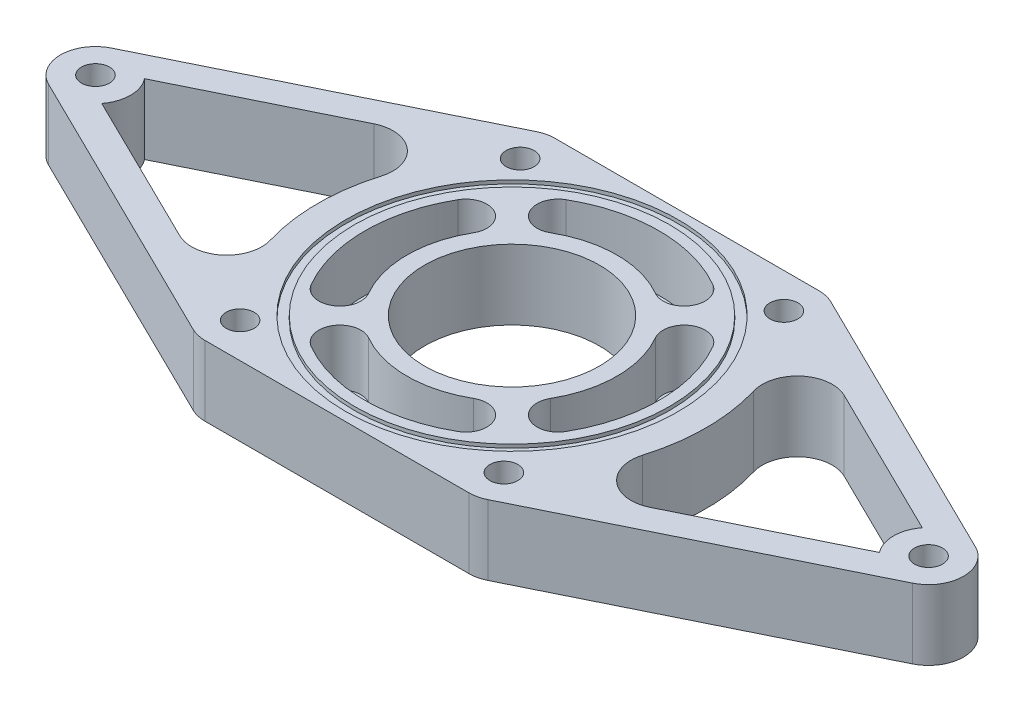
from build123d import *

# Parameters (mm, degrees)
BOSS_EXTRUDE1_DEPTH = 20
SKETCH2_R           = 47.5
SKETCH2_R_2         = 45
CUT_EXTRUDE1_DEPTH  = 1
CUT_EXTRUDE2_DEPTH  = 16
CIRPATTERN1_COUNT   = 4
SKETCH4_R           = 25
CUT_EXTRUDE3_DEPTH  = 21
SKETCH6_R           = 4
CUT_EXTRUDE4_DEPTH  = 21
CUT_EXTRUDE5_DEPTH  = 21
FILLET1_R           = 10
SKETCH9_R           = 4
CUT_EXTRUDE6_DEPTH  = 21


with BuildPart() as part:
    # Sketch1 → Boss-Extrude1 (new body)
    with BuildSketch(Plane(origin=(0, 0, 0), x_dir=(1, 0, 0), z_dir=(0, 1, 0))):
        with BuildLine():
            Line((-40, -50), (40, -50))
            Line((40, -50), (123.413509856, -8.973345572))
            ThreePointArc((123.413509856, -8.973345572), (129, 0), (123.413509856, 8.973345572))
            Line((123.413509856, 8.973345572), (40, 50))
            Line((40, 50), (-40, 50))
            Line((-40, 50), (-123.413509856, 8.973345572))
            ThreePointArc((-123.413509856, 8.973345572), (-129, 0), (-123.413509856, -8.973345572))
            Line((-123.413509856, -8.973345572), (-40, -50))
        make_face()
    extrude(amount=BOSS_EXTRUDE1_DEPTH)

    # Sketch2 → Cut-Extrude1 (cut)
    with BuildSketch(Plane(origin=(0, 20, 0), x_dir=(1, 0, 0), z_dir=(0, 1, 0))):
        with Locations(Location((0, 0, 0), (0, 0, 270))):  # turned: the seam where the file's is
            Circle(SKETCH2_R)
        with Locations(Location((0, 0, 0), (0, 0, 270))):  # turned: the seam where the file's is
            Circle(SKETCH2_R_2, mode=Mode.SUBTRACT)
    extrude(amount=-CUT_EXTRUDE1_DEPTH, mode=Mode.SUBTRACT)

    # Sketch3 → Cut-Extrude2 (cut)
    with BuildSketch(Plane(origin=(0, 20, 0), x_dir=(1, 0, 0), z_dir=(0, 1, 0))):
        with BuildLine():
            ThreePointArc((36.373066959, -21), (42, 0), (36.373066959, 21))
            ThreePointArc((36.373066959, 21), (28.176914536, 23.196152423), (25.980762114, 15))
            ThreePointArc((25.980762114, 15), (30, 0), (25.980762114, -15))
            ThreePointArc((25.980762114, -15), (28.176914536, -23.196152423), (36.373066959, -21))
        make_face()
    cut_extrude2 = extrude(amount=-CUT_EXTRUDE2_DEPTH, mode=Mode.SUBTRACT)

    # CirPattern1: Cut-Extrude2 ×4 about axis
    cirpattern1_axis = Axis((0, 0, 0), (0, 1, 0))
    for i in range(1, CIRPATTERN1_COUNT):
        add(cut_extrude2.rotate(cirpattern1_axis, i * 360 / CIRPATTERN1_COUNT), mode=Mode.SUBTRACT)

    # Sketch4 → Cut-Extrude3 (cut, through all)
    with BuildSketch(Plane(origin=(0, 20, 0), x_dir=(1, 0, 0), z_dir=(0, 1, 0))):
        with Locations(Location((0, 0, 0), (0, 0, 270))):  # turned: the seam where the file's is
            Circle(SKETCH4_R)
    extrude(amount=-CUT_EXTRUDE3_DEPTH, mode=Mode.SUBTRACT)

    # Sketch6 → Cut-Extrude4 (cut, through all)
    with BuildSketch(Plane(origin=(0, 20, 0), x_dir=(1, 0, 0), z_dir=(0, 1, 0))):
        with Locations(Location((-119, 0, 0), (0, 0, 270))):  # turned: the seam where the file's is
            Circle(SKETCH6_R)
        with Locations(Location((119, 0, 0), (0, 0, 270))):  # turned: the seam where the file's is
            Circle(SKETCH6_R)
    extrude(amount=-CUT_EXTRUDE4_DEPTH, mode=Mode.SUBTRACT)

    # Sketch8 → Cut-Extrude5 (cut, through all)
    with BuildSketch(Plane(origin=(0, 20, 0), x_dir=(1, 0, 0), z_dir=(0, 1, 0))):
        with BuildLine():
            Line((-67.173638652, 27.719444727), (-111.090654796, 6.119007963))
            ThreePointArc((-111.090654796, 6.119007963), (-109, 0), (-111.090654796, -6.119007963))
            Line((-111.090654796, -6.119007963), (-67.173638652, -27.719444727))
            ThreePointArc((-67.173638652, -27.719444727), (-56.30285419, -26.381778867), (-53.178429743, -15.884099284))
            ThreePointArc((-53.178429743, -15.884099284), (-55.5, 0), (-53.178429743, 15.884099284))
            ThreePointArc((-53.178429743, 15.884099284), (-56.30285419, 26.381778867), (-67.173638652, 27.719444727))
        make_face()
    cut_extrude5 = extrude(amount=-CUT_EXTRUDE5_DEPTH, mode=Mode.SUBTRACT)

    # Mirror1: Cut-Extrude5 across plane
    add(cut_extrude5.mirror(Plane(origin=(0, 0, 0), x_dir=(0, 0, 1), z_dir=(1, 0, 0))), mode=Mode.SUBTRACT)

    # Fillet1
    fillet1_edges = [part.edges().sort_by_distance(p)[0] for p in [
        (40, 10, 50),
        (-40, 10, 50),
        (-40, 10, -50),
        (40, 10, -50),
    ]]
    fillet(fillet1_edges, radius=FILLET1_R)

    # Sketch9 → Cut-Extrude6 (cut, through all)
    with BuildSketch(Plane(origin=(0, 20, 0), x_dir=(1, 0, 0), z_dir=(0, 1, 0))):
        with Locations(Location((-37.673836784, 40, 0), (0, 0, 270))):  # turned: the seam where the file's is
            Circle(SKETCH9_R)
        with Locations(Location((37.673836784, 40, 0), (0, 0, 270))):  # turned: the seam where the file's is
            Circle(SKETCH9_R)
        with Locations(Location((-37.673836784, -40, 0), (0, 0, 270))):  # turned: the seam where the file's is
            Circle(SKETCH9_R)
        with Locations(Location((37.673836784, -40, 0), (0, 0, 270))):  # turned: the seam where the file's is
            Circle(SKETCH9_R)
    extrude(amount=-CUT_EXTRUDE6_DEPTH, mode=Mode.SUBTRACT)


solid = part.part
